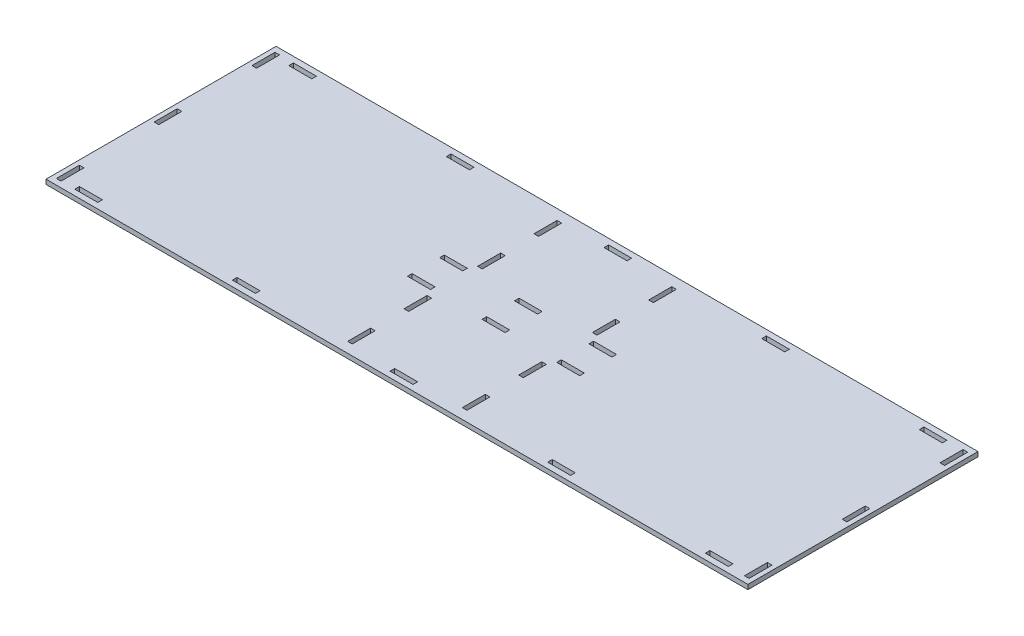
from build123d import *

# Parameters (mm, degrees)
SKETCH1_W           = 610
SKETCH1_H           = 200
SKETCH1_W_2         = 4
SKETCH1_H_2         = 20
SKETCH1_W_3         = 20
SKETCH1_H_3         = 4
BOSS_EXTRUDE1_DEPTH = 4


with BuildPart() as part:
    # Sketch1 → Boss-Extrude1 (new body)
    with BuildSketch(Plane(origin=(0, 0, 0), x_dir=(1, 0, 0), z_dir=(0, 1, 0))):
        Rectangle(SKETCH1_W, SKETCH1_H)
        with Locations((-299, -85)):
            Rectangle(SKETCH1_W_2, SKETCH1_H_2, mode=Mode.SUBTRACT)
        with Locations((-299, 85)):
            Rectangle(SKETCH1_W_2, SKETCH1_H_2, mode=Mode.SUBTRACT)
        with Locations((-299, 0)):
            Rectangle(SKETCH1_W_2, SKETCH1_H_2, mode=Mode.SUBTRACT)
        with Locations((-275, 93)):
            Rectangle(SKETCH1_W_3, SKETCH1_H_3, mode=Mode.SUBTRACT)
        with Locations((-138, 93)):
            Rectangle(SKETCH1_W_3, SKETCH1_H_3, mode=Mode.SUBTRACT)
        with Locations((-1, 93)):
            Rectangle(SKETCH1_W_3, SKETCH1_H_3, mode=Mode.SUBTRACT)
        with Locations((-1, -93)):
            Rectangle(SKETCH1_W_3, SKETCH1_H_3, mode=Mode.SUBTRACT)
        with Locations((-138, -93)):
            Rectangle(SKETCH1_W_3, SKETCH1_H_3, mode=Mode.SUBTRACT)
        with Locations((-275, -93)):
            Rectangle(SKETCH1_W_3, SKETCH1_H_3, mode=Mode.SUBTRACT)
        with Locations((-49.859697176, -81)):
            Rectangle(SKETCH1_W_2, SKETCH1_H_2, mode=Mode.SUBTRACT)
        with Locations((-49.859697176, -32)):
            Rectangle(SKETCH1_W_2, SKETCH1_H_2, mode=Mode.SUBTRACT)
        with Locations((-64.859697176, -14)):
            Rectangle(SKETCH1_W_3, SKETCH1_H_3, mode=Mode.SUBTRACT)
        with Locations((-64.859697176, 14)):
            Rectangle(SKETCH1_W_3, SKETCH1_H_3, mode=Mode.SUBTRACT)
        with Locations((-49.859697176, 32)):
            Rectangle(SKETCH1_W_2, SKETCH1_H_2, mode=Mode.SUBTRACT)
        with Locations((0, -14)):
            Rectangle(SKETCH1_W_3, SKETCH1_H_3, mode=Mode.SUBTRACT)
        with Locations((0.140302824, 14)):
            Rectangle(SKETCH1_W_3, SKETCH1_H_3, mode=Mode.SUBTRACT)
        with Locations((136, 93)):
            Rectangle(SKETCH1_W_3, SKETCH1_H_3, mode=Mode.SUBTRACT)
        with Locations((273, 93)):
            Rectangle(SKETCH1_W_3, SKETCH1_H_3, mode=Mode.SUBTRACT)
        with Locations((49.859697176, -81)):
            Rectangle(SKETCH1_W_2, SKETCH1_H_2, mode=Mode.SUBTRACT)
        with Locations((49.859697176, -32)):
            Rectangle(SKETCH1_W_2, SKETCH1_H_2, mode=Mode.SUBTRACT)
        with Locations((64.859697176, -14)):
            Rectangle(SKETCH1_W_3, SKETCH1_H_3, mode=Mode.SUBTRACT)
        with Locations((64.859697176, 14)):
            Rectangle(SKETCH1_W_3, SKETCH1_H_3, mode=Mode.SUBTRACT)
        with Locations((49.859697176, 32)):
            Rectangle(SKETCH1_W_2, SKETCH1_H_2, mode=Mode.SUBTRACT)
        with Locations((273, -93)):
            Rectangle(SKETCH1_W_3, SKETCH1_H_3, mode=Mode.SUBTRACT)
        with Locations((136, -93)):
            Rectangle(SKETCH1_W_3, SKETCH1_H_3, mode=Mode.SUBTRACT)
        with Locations((49.859697176, 81)):
            Rectangle(SKETCH1_W_2, SKETCH1_H_2, mode=Mode.SUBTRACT)
        with Locations((-49.859697176, 81)):
            Rectangle(SKETCH1_W_2, SKETCH1_H_2, mode=Mode.SUBTRACT)
        with Locations((299, 85)):
            Rectangle(SKETCH1_W_2, SKETCH1_H_2, mode=Mode.SUBTRACT)
        with Locations((299, 0)):
            Rectangle(SKETCH1_W_2, SKETCH1_H_2, mode=Mode.SUBTRACT)
        with Locations((299, -85)):
            Rectangle(SKETCH1_W_2, SKETCH1_H_2, mode=Mode.SUBTRACT)
    extrude(amount=BOSS_EXTRUDE1_DEPTH)


solid = part.part
